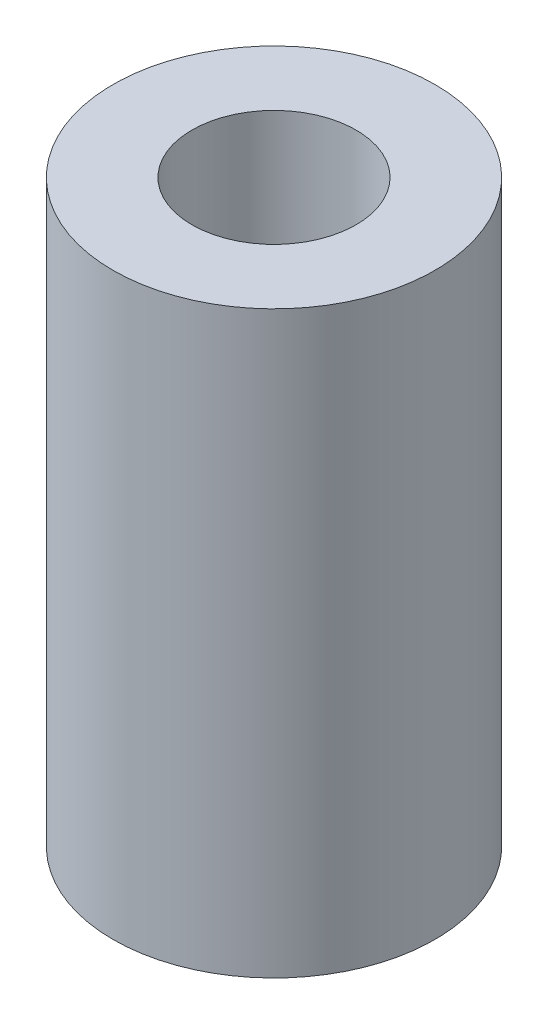
from build123d import *

# Parameters (mm, degrees)
SKETCH1_R           = 6.35
BOSS_EXTRUDE1_DEPTH = 22.86
SKETCH2_R           = 3.048
CUT_EXTRUDE1_DEPTH  = 8.636
SKETCH3_R           = 3.2385
CUT_EXTRUDE2_DEPTH  = 10.16


with BuildPart() as part:
    # Sketch1 → Boss-Extrude1 (new body)
    with BuildSketch(Plane(origin=(0, 0, 0), x_dir=(1, 0, 0), z_dir=(0, 1, 0))):
        Circle(SKETCH1_R)
    extrude(amount=BOSS_EXTRUDE1_DEPTH)

    # Sketch2 → Cut-Extrude1 (cut)
    with BuildSketch(Plane.XZ):
        Circle(SKETCH2_R)
    extrude(amount=-CUT_EXTRUDE1_DEPTH, mode=Mode.SUBTRACT)

    # Sketch3 → Cut-Extrude2 (cut)
    with BuildSketch(Plane(origin=(0, 22.86, 0), x_dir=(1, 0, 0), z_dir=(0, 1, 0))):
        Circle(SKETCH3_R)
    extrude(amount=-CUT_EXTRUDE2_DEPTH, mode=Mode.SUBTRACT)


solid = part.part
